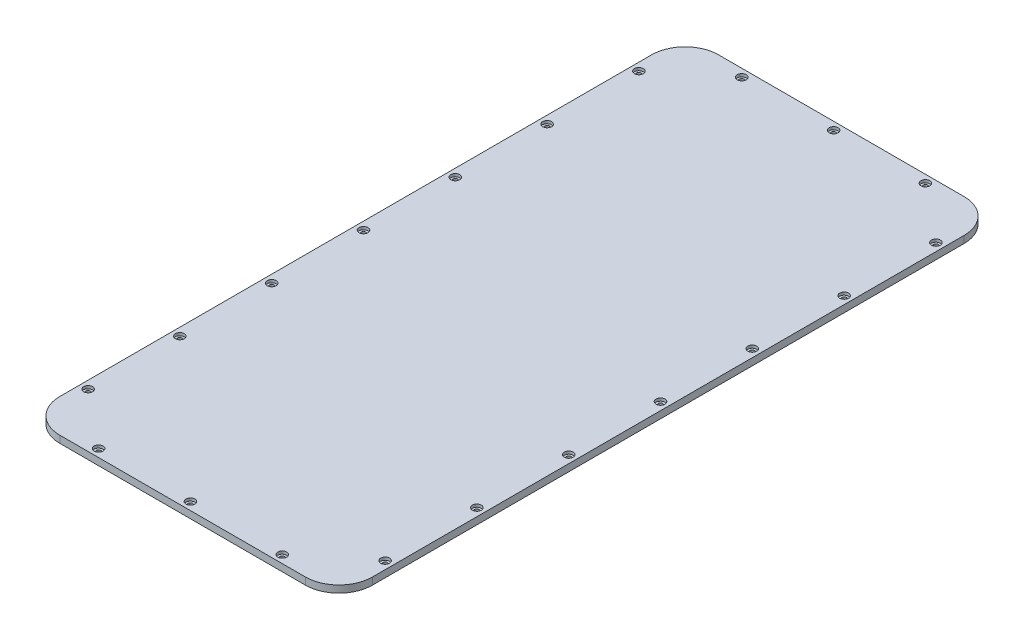
from build123d import *

# Parameters (mm, degrees)
SKETCH1_R           = 2.1
BOSS_EXTRUDE1_DEPTH = 6.35
SKETCH3_R           = 4
CUT_EXTRUDE1_DEPTH  = 2.5


with BuildPart() as part:
    # Sketch1 → Boss-Extrude1 (new body)
    with BuildSketch(Plane(origin=(0, 0, 0), x_dir=(-1, 0, 0), z_dir=(0, 1, 0))):
        with BuildLine():
            Line((90.927407972, 302.93116582), (-129.072592028, 302.93116582))
            ThreePointArc((-129.072592028, 302.93116582), (-150.285795463, 294.144369255), (-159.072592028, 272.93116582))
            Line((-159.072592028, 272.93116582), (-159.072592028, -257.06883418))
            ThreePointArc((-159.072592028, -257.06883418), (-150.285795463, -278.282037616), (-129.072592028, -287.06883418))
            Line((-129.072592028, -287.06883418), (90.927407972, -287.06883418))
            ThreePointArc((90.927407972, -287.06883418), (112.140611408, -278.282037616), (120.927407972, -257.06883418))
            Line((120.927407972, -257.06883418), (120.927407972, 272.93116582))
            ThreePointArc((120.927407972, 272.93116582), (112.140611408, 294.144369255), (90.927407972, 302.93116582))
        make_face()
        with Locations((-152.072592028, 254.608155129)):
            Circle(SKETCH1_R, mode=Mode.SUBTRACT)
        with Locations((-101.298255131, 295.93116582)):
            Circle(SKETCH1_R, mode=Mode.SUBTRACT)
        with Locations((-19.072592028, 295.93116582)):
            Circle(SKETCH1_R, mode=Mode.SUBTRACT)
        with Locations((63.153071075, 295.93116582)):
            Circle(SKETCH1_R, mode=Mode.SUBTRACT)
        with Locations((113.927407972, 254.608155129)):
            Circle(SKETCH1_R, mode=Mode.SUBTRACT)
        with Locations((-152.072592028, 7.93116582)):
            Circle(SKETCH1_R, mode=Mode.SUBTRACT)
        with Locations((-152.072592028, -74.294497284)):
            Circle(SKETCH1_R, mode=Mode.SUBTRACT)
        with Locations((-152.072592028, -156.520160387)):
            Circle(SKETCH1_R, mode=Mode.SUBTRACT)
        with Locations((-152.072592028, -238.74582349)):
            Circle(SKETCH1_R, mode=Mode.SUBTRACT)
        with Locations((-101.298255131, -280.06883418)):
            Circle(SKETCH1_R, mode=Mode.SUBTRACT)
        with Locations((-19.072592028, -280.06883418)):
            Circle(SKETCH1_R, mode=Mode.SUBTRACT)
        with Locations((63.153071075, -280.06883418)):
            Circle(SKETCH1_R, mode=Mode.SUBTRACT)
        with Locations((113.927407972, -238.74582349)):
            Circle(SKETCH1_R, mode=Mode.SUBTRACT)
        with Locations((113.927407972, -156.520160387)):
            Circle(SKETCH1_R, mode=Mode.SUBTRACT)
        with Locations((113.927407972, -74.294497284)):
            Circle(SKETCH1_R, mode=Mode.SUBTRACT)
        with Locations((113.927407972, 7.93116582)):
            Circle(SKETCH1_R, mode=Mode.SUBTRACT)
        with Locations((-152.072592028, 90.156828923)):
            Circle(SKETCH1_R, mode=Mode.SUBTRACT)
        with Locations((-152.072592028, 172.382492026)):
            Circle(SKETCH1_R, mode=Mode.SUBTRACT)
        with Locations((113.927407972, 90.156828923)):
            Circle(SKETCH1_R, mode=Mode.SUBTRACT)
        with Locations((113.927407972, 172.382492026)):
            Circle(SKETCH1_R, mode=Mode.SUBTRACT)
    extrude(amount=BOSS_EXTRUDE1_DEPTH)

    # Sketch3 → Cut-Extrude1 (cut)
    with BuildSketch(Plane(origin=(0, 6.35, 0), x_dir=(1, 0, 0), z_dir=(0, 1, 0))):
        with Locations((152.072592028, -254.608155129)):
            Circle(SKETCH3_R)
        with Locations((101.298255131, -295.93116582)):
            Circle(SKETCH3_R)
        with Locations((19.072592028, -295.93116582)):
            Circle(SKETCH3_R)
        with Locations((-63.153071075, -295.93116582)):
            Circle(SKETCH3_R)
        with Locations((-113.927407972, -254.608155129)):
            Circle(SKETCH3_R)
        with Locations((-113.927407972, -172.382492026)):
            Circle(SKETCH3_R)
        with Locations((-113.927407972, -90.156828923)):
            Circle(SKETCH3_R)
        with Locations((-113.927407972, -7.93116582)):
            Circle(SKETCH3_R)
        with Locations((-113.927407972, 74.294497284)):
            Circle(SKETCH3_R)
        with Locations((-113.927407972, 156.520160387)):
            Circle(SKETCH3_R)
        with Locations((-113.927407972, 238.74582349)):
            Circle(SKETCH3_R)
        with Locations((-63.153071075, 280.06883418)):
            Circle(SKETCH3_R)
        with Locations((19.072592028, 280.06883418)):
            Circle(SKETCH3_R)
        with Locations((101.298255131, 280.06883418)):
            Circle(SKETCH3_R)
        with Locations((152.072592028, 238.74582349)):
            Circle(SKETCH3_R)
        with Locations((152.072592028, 156.520160387)):
            Circle(SKETCH3_R)
        with Locations((152.072592028, 74.294497284)):
            Circle(SKETCH3_R)
        with Locations((152.072592028, -7.93116582)):
            Circle(SKETCH3_R)
        with Locations((152.072592028, -90.156828923)):
            Circle(SKETCH3_R)
        with Locations((152.072592028, -172.382492026)):
            Circle(SKETCH3_R)
    extrude(amount=-CUT_EXTRUDE1_DEPTH, mode=Mode.SUBTRACT)


solid = part.part
